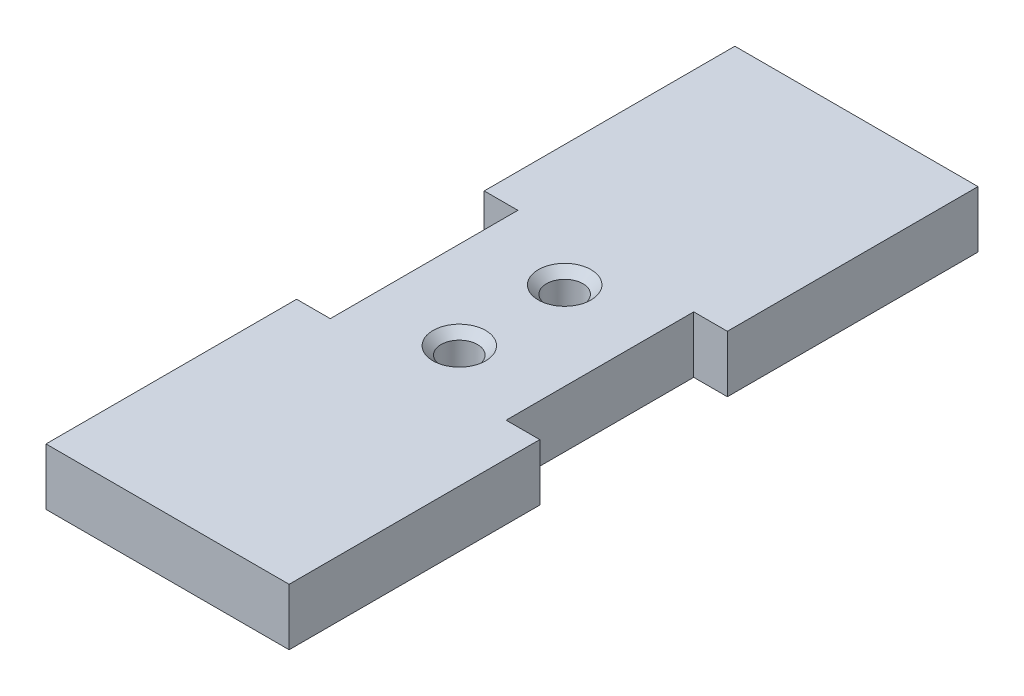
from build123d import *

# Parameters (mm, degrees)
SKETCH1_W           = 30
SKETCH1_H           = 85
BOSS_EXTRUDE1_DEPTH = 7
SKETCH2_W           = 4.15
SKETCH2_H           = 23.15
CUT_EXTRUDE1_DEPTH  = 8
SKETCH3_R           = 2.25
CUT_EXTRUDE2_DEPTH  = 8
CHAMFER1_SIZE       = 1


with BuildPart() as part:
    # Sketch1 → Boss-Extrude1 (new body)
    with BuildSketch(Plane(origin=(0, 0, 0), x_dir=(1, 0, 0), z_dir=(0, 1, 0))):
        with Locations((15, 42.5)):
            Rectangle(SKETCH1_W, SKETCH1_H)
    extrude(amount=BOSS_EXTRUDE1_DEPTH)

    # Sketch2 → Cut-Extrude1 (cut, through all)
    with BuildSketch(Plane(origin=(0, 7, 0), x_dir=(1, 0, 0), z_dir=(0, 1, 0))):
        with Locations((2.075, 42.5)):
            Rectangle(SKETCH2_W, SKETCH2_H)
        with Locations((27.925, 42.5)):
            Rectangle(SKETCH2_W, SKETCH2_H)
    extrude(amount=-CUT_EXTRUDE1_DEPTH, mode=Mode.SUBTRACT)

    # Sketch3 → Cut-Extrude2 (cut, through all)
    with BuildSketch(Plane(origin=(0, 7, 0), x_dir=(1, 0, 0), z_dir=(0, 1, 0))):
        with Locations((15, 49)):
            Circle(SKETCH3_R)
        with Locations((15, 36)):
            Circle(SKETCH3_R)
    extrude(amount=-CUT_EXTRUDE2_DEPTH, mode=Mode.SUBTRACT)

    # Chamfer1
    chamfer1_edges = [part.edges().sort_by_distance(p)[0] for p in [
        (12.75, 7, -49),
        (12.75, 7, -36),
    ]]
    chamfer(chamfer1_edges, length=CHAMFER1_SIZE)


solid = part.part
